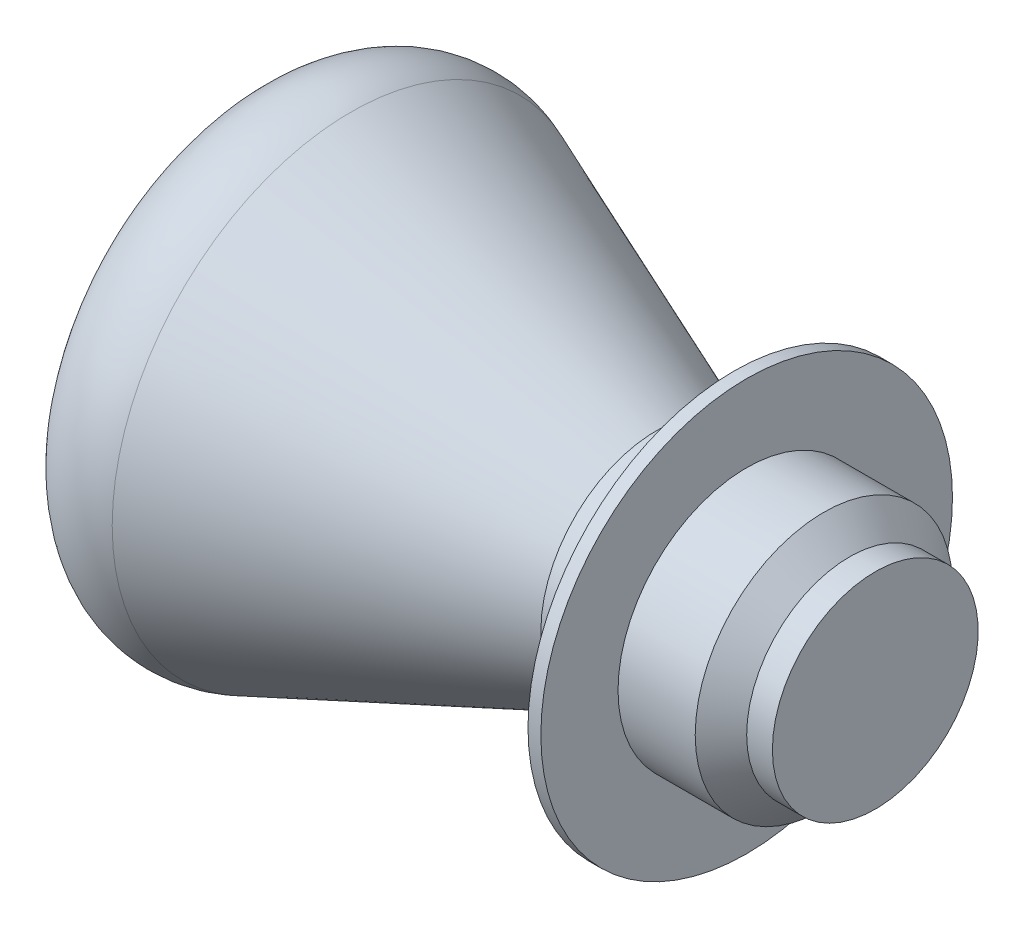
from build123d import *


with BuildPart() as part:
    # Sketch2 → Revolve1 (revolve)
    with BuildSketch(Plane.XY):
        Polygon((5.5, 0), (5.5, 4), (4.5, 4), (3.5, 5), (0.5, 5), (0.5, 8), (0, 8), (0, 5), (-2, 5), (-2, 0), align=None)
    revolve(axis=Axis((-2, 0, 0), (1, 0, 0)))

    # Sketch4 → Revolve2 (revolve)
    with BuildSketch(Plane.XY):
        with BuildLine():
            Line((0, 4.5), (-3, 4.5))
            Line((-3, 4.5), (-14.879552076, 9.282911506))
            ThreePointArc((-14.879552076, 9.282911506), (-17.339156162, 9.184522448), (-18.897161062, 7.278753994))
            ThreePointArc((-18.897161062, 7.278753994), (-19.617023423, 3.670972882), (-19.858362338, 0))
            Line((-19.858362338, 0), (0, 0))
            Line((0, 0), (0, 4.5))
        make_face()
    revolve(axis=Axis((0, 0, 0), (-1, 0, 0)))


solid = part.part
